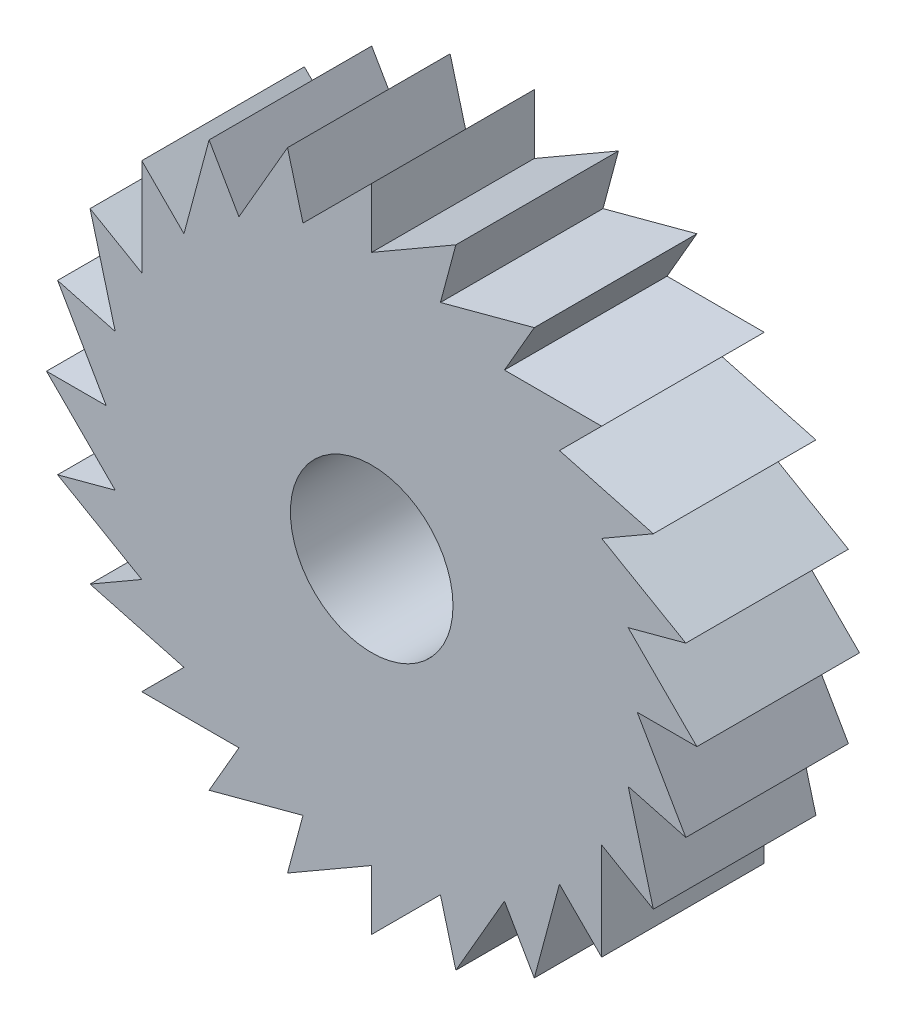
from build123d import *

# Parameters (mm, degrees)
SKETCH1_R           = 3.175
BOSS_EXTRUDE1_DEPTH = 6.35


with BuildPart() as part:
    # Sketch1 → Boss-Extrude1 (new body)
    with BuildSketch(Plane.XY):
        Polygon((0, 12.7), (-2.683825791, 10.016174209), (-3.287001873, 12.267257994), (-5.184753289, 8.980256121), (-6.35, 10.998522628), (-7.332348419, 7.332348419), (-8.980256121, 8.980256121), (-8.980256121, 5.184753289), (-10.998522628, 6.35), (-10.016174209, 2.683825791), (-12.267257994, 3.287001873), (-10.369506578, 0), (-12.7, 0), (-10.016174209, -2.683825791), (-12.267257994, -3.287001873), (-8.980256121, -5.184753289), (-10.998522628, -6.35), (-7.332348419, -7.332348419), (-8.980256121, -8.980256121), (-5.184753289, -8.980256121), (-6.35, -10.998522628), (-2.683825791, -10.016174209), (-3.287001873, -12.267257994), (0, -10.369506578), (0, -12.7), (2.683825791, -10.016174209), (3.287001873, -12.267257994), (5.184753289, -8.980256121), (6.35, -10.998522628), (7.332348419, -7.332348419), (8.980256121, -8.980256121), (8.980256121, -5.184753289), (10.998522628, -6.35), (10.016174209, -2.683825791), (12.267257994, -3.287001873), (10.369506578, 0), (12.7, 0), (10.016174209, 2.683825791), (12.267257994, 3.287001873), (8.980256121, 5.184753289), (10.998522628, 6.35), (7.332348419, 7.332348419), (8.980256121, 8.980256121), (5.184753289, 8.980256121), (6.35, 10.998522628), (2.683825791, 10.016174209), (3.287001873, 12.267257994), (0, 10.369506578), align=None)
        Circle(SKETCH1_R, mode=Mode.SUBTRACT)
    extrude(amount=BOSS_EXTRUDE1_DEPTH)


solid = part.part
